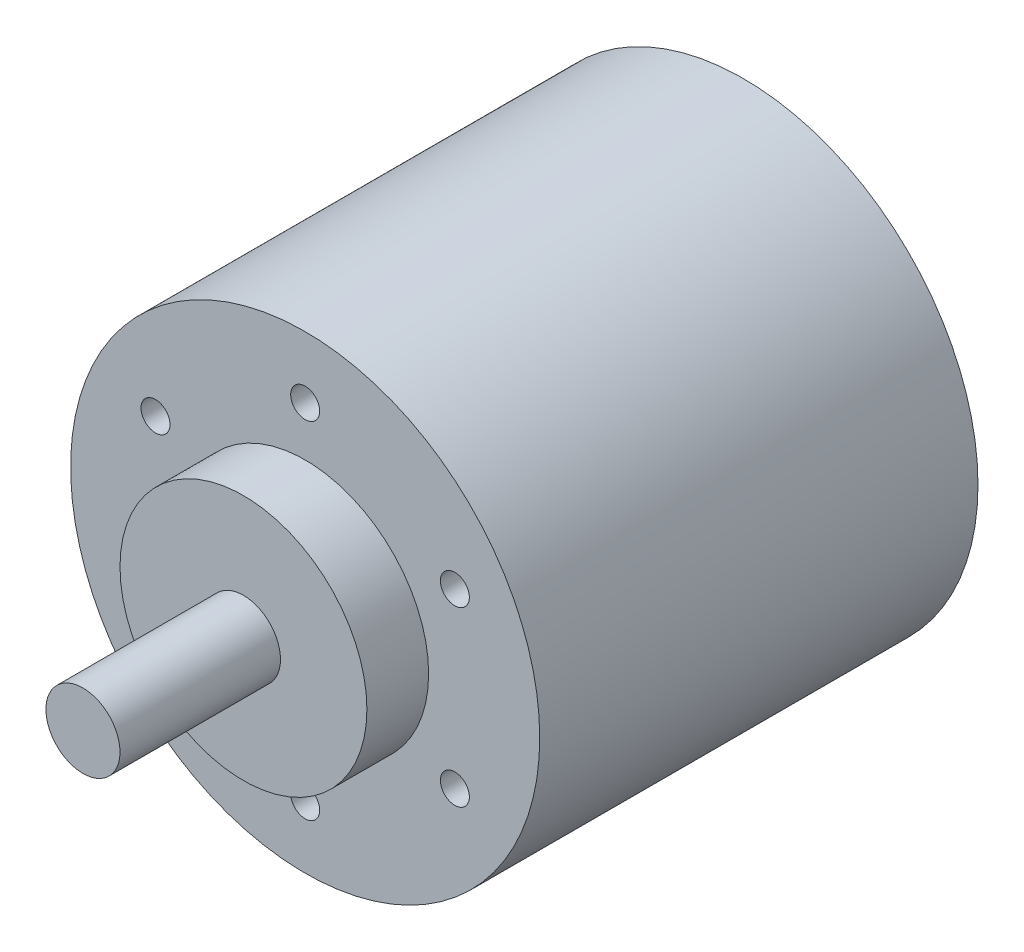
from build123d import *

# Parameters (mm, degrees)
SKETCH1_R           = 19
BOSS_EXTRUDE1_DEPTH = 35.5
SKETCH2_R           = 10
BOSS_EXTRUDE2_DEPTH = 5
SKETCH3_R           = 3
BOSS_EXTRUDE3_DEPTH = 13
SKETCH4_R           = 1.174286688
CUT_EXTRUDE1_DEPTH  = 5
CIRPATTERN1_COUNT   = 6


with BuildPart() as part:
    # Sketch1 → Boss-Extrude1 (new body)
    with BuildSketch(Plane.XY):
        Circle(SKETCH1_R)
    extrude(amount=-BOSS_EXTRUDE1_DEPTH)

    # Sketch2 → Boss-Extrude2 (add)
    with BuildSketch(Plane.XY):
        Circle(SKETCH2_R)
    extrude(amount=BOSS_EXTRUDE2_DEPTH)

    # Sketch3 → Boss-Extrude3 (add)
    with BuildSketch(Plane.XY.offset(5)):
        Circle(SKETCH3_R)
    extrude(amount=BOSS_EXTRUDE3_DEPTH)

    # Sketch4 → Cut-Extrude1 (cut)
    with BuildSketch(Plane.XY):
        with Locations((0, 14)):
            Circle(SKETCH4_R)
    cut_extrude1 = extrude(amount=-CUT_EXTRUDE1_DEPTH, mode=Mode.SUBTRACT)

    # CirPattern1: Cut-Extrude1 ×6 about axis
    cirpattern1_axis = Axis((0, 0, 0), (0, 0, 1))
    for i in range(1, CIRPATTERN1_COUNT):
        add(cut_extrude1.rotate(cirpattern1_axis, i * 360 / CIRPATTERN1_COUNT), mode=Mode.SUBTRACT)


solid = part.part
